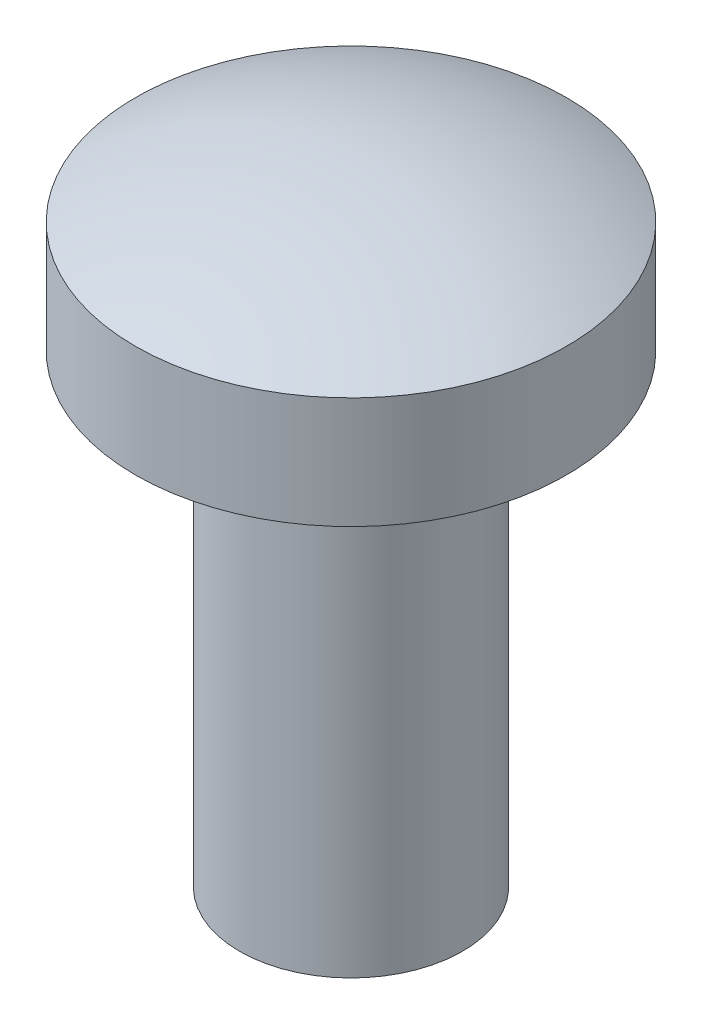
from build123d import *


with BuildPart() as part:
    # Sketch1 → Revolve1 (revolve)
    with BuildSketch(Plane(origin=(0, 0, 0), x_dir=(0, 0, -1), z_dir=(1, 0, 0)), mode=Mode.PRIVATE) as revolve1_sk:
        with BuildLine():
            Line((0, 1.1176), (0, -3.175))
            Line((0, -3.175), (0.762, -3.175))
            Line((0.762, -3.175), (0.762, 0))
            Line((0.762, 0), (1.4732, 0))
            Line((1.4732, 0), (1.4732, 0.762))
            ThreePointArc((1.4732, 0.762), (0.757754842, 1.027441487), (0, 1.1176))
        make_face()
    revolve(revolve1_sk.sketch.rotate(Axis((0, 58.600892857, 0), (0, -1, 0)), 180), axis=Axis((0, 58.600892857, 0), (0, -1, 0)))  # turned: the seam where the file's is


solid = part.part
